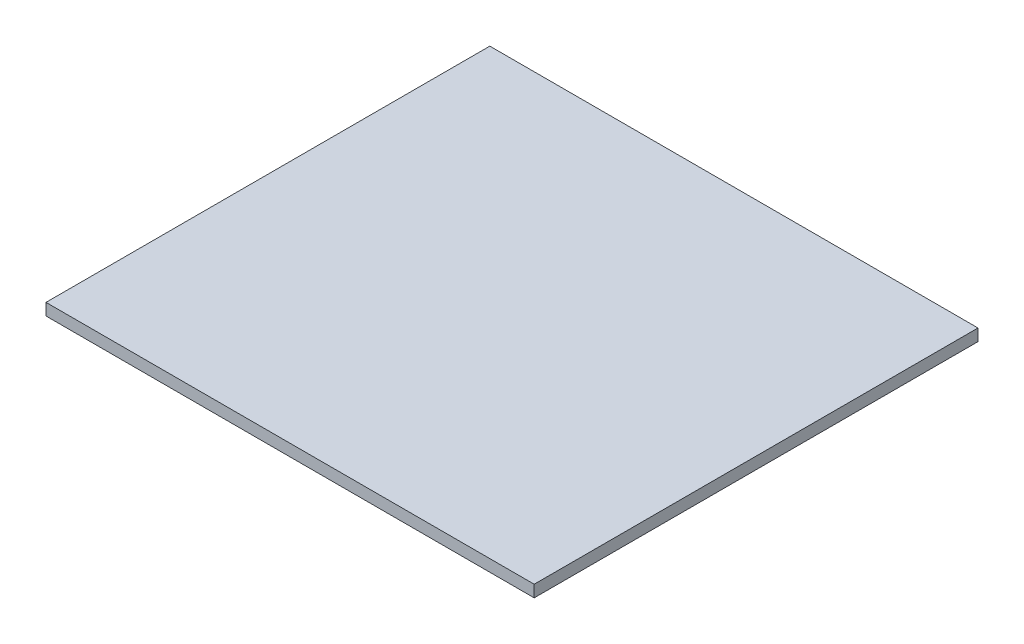
from build123d import *

# Parameters (mm, degrees)
SKETCH1_W           = 165
SKETCH1_H           = 150
BOSS_EXTRUDE1_DEPTH = 4


with BuildPart() as part:
    # Sketch1 → Boss-Extrude1 (new body)
    with BuildSketch(Plane(origin=(0, 0, 0), x_dir=(1, 0, 0), z_dir=(0, 1, 0))):
        with Locations((82.5, 75)):
            Rectangle(SKETCH1_W, SKETCH1_H)
    extrude(amount=BOSS_EXTRUDE1_DEPTH)


solid = part.part
